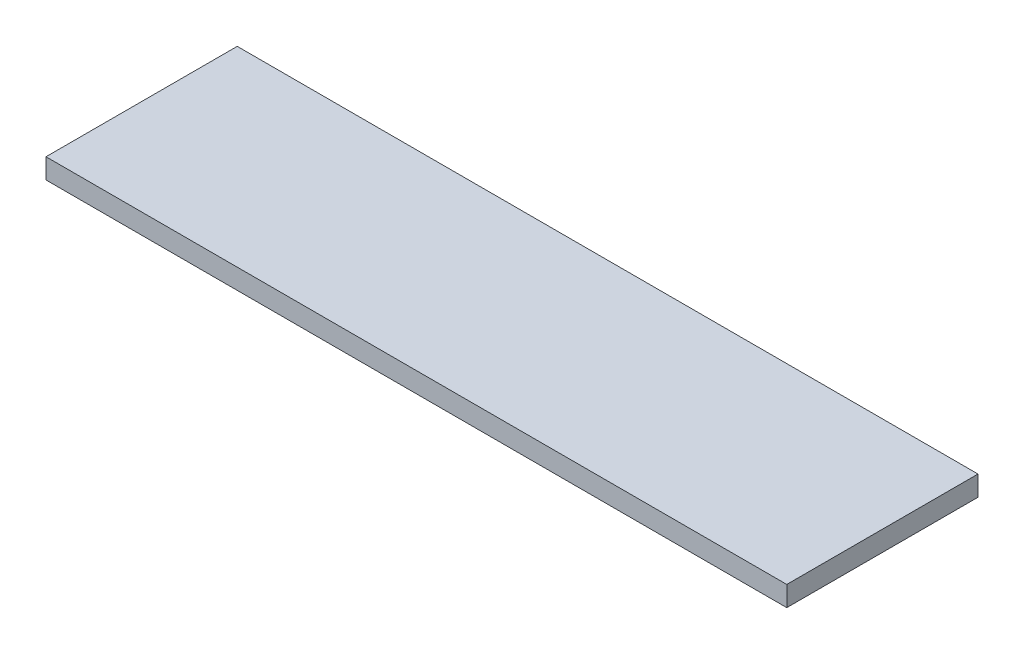
from build123d import *

# Parameters (mm, degrees)
SKETCH1_W           = 368
SKETCH1_H           = 95
BOSS_EXTRUDE1_DEPTH = 10


with BuildPart() as part:
    # Sketch1 → Boss-Extrude1 (new body)
    with BuildSketch(Plane(origin=(0, 0, 0), x_dir=(1, 0, 0), z_dir=(0, 1, 0))):
        Rectangle(SKETCH1_W, SKETCH1_H)
    extrude(amount=BOSS_EXTRUDE1_DEPTH)


solid = part.part
